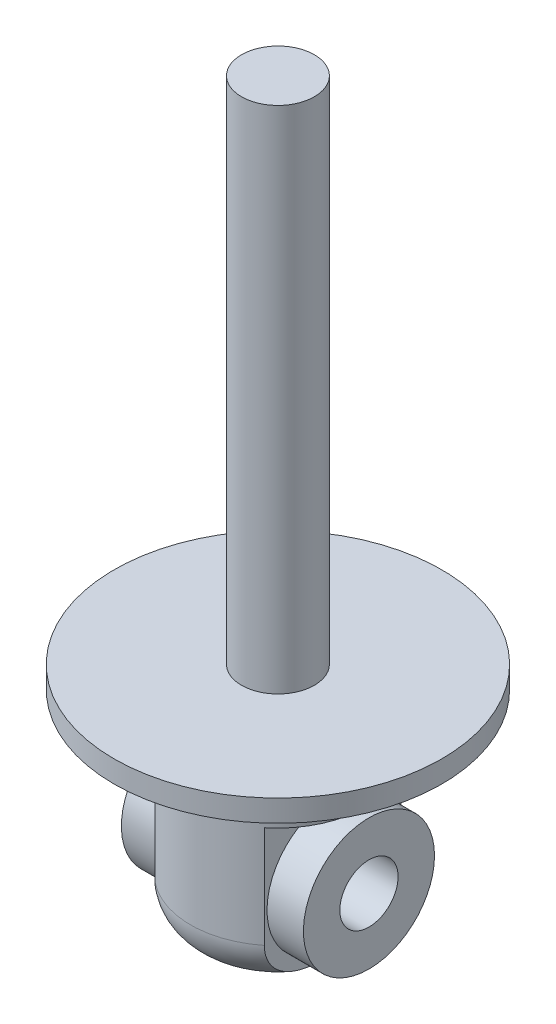
from build123d import *

# Parameters (mm, degrees)
SKETCH1_R               = 22.5
BOSS_EXTRUDE1_DEPTH     = 3
SKETCH2_R               = 5
BOSS_EXTRUDE2_DEPTH     = 70
SKETCH3_R               = 12
BOSS_EXTRUDE3_DEPTH     = 28
FILLET1_R               = 6
SKETCH4_W               = 19.983426231
SKETCH4_H               = 20
CUT_EXTRUDE1_DEPTH      = 23.5
CUT_EXTRUDE1_DEPTH_BACK = 23.5
SKETCH5_R               = 4
CUT_EXTRUDE2_DEPTH      = 16
CUT_EXTRUDE2_DEPTH_BACK = 31
SKETCH7_R               = 9
SKETCH7_R_2             = 4
BOSS_EXTRUDE5_DEPTH     = 12.5


with BuildPart() as part:
    # Sketch1 → Boss-Extrude1 (new body)
    with BuildSketch(Plane(origin=(0, 0, 0), x_dir=(1, 0, 0), z_dir=(0, 1, 0))):
        Circle(SKETCH1_R)
    extrude(amount=BOSS_EXTRUDE1_DEPTH)

    # Sketch2 → Boss-Extrude2 (add)
    with BuildSketch(Plane(origin=(0, 3, 0), x_dir=(1, 0, 0), z_dir=(0, 1, 0))):
        Circle(SKETCH2_R)
    extrude(amount=BOSS_EXTRUDE2_DEPTH)

    # Sketch3 → Boss-Extrude3 (add)
    with BuildSketch(Plane.XZ):
        Circle(SKETCH3_R)
    extrude(amount=BOSS_EXTRUDE3_DEPTH)

    # Fillet1
    fillet1_edges = [part.edges().sort_by_distance(p)[0] for p in [
        (-12, -28, 0),
    ]]
    fillet(fillet1_edges, radius=FILLET1_R)

    # Sketch4 → Cut-Extrude1 (cut, two sides)
    with BuildSketch(Plane.XY) as cut_extrude1_sk:
        with Locations((17.491713116, -18)):
            Rectangle(SKETCH4_W, SKETCH4_H)
        with Locations((-17.491713116, -18)):
            Rectangle(SKETCH4_W, SKETCH4_H)
    extrude(amount=CUT_EXTRUDE1_DEPTH, mode=Mode.SUBTRACT)
    extrude(cut_extrude1_sk.sketch, amount=-CUT_EXTRUDE1_DEPTH_BACK, mode=Mode.SUBTRACT)

    # Sketch5 → Cut-Extrude2 (cut, two sides)
    with BuildSketch(Plane(origin=(7.5, 0, 0), x_dir=(0, 0, -1), z_dir=(1, 0, 0))) as cut_extrude2_sk:
        with Locations((0, -18)):
            Circle(SKETCH5_R)
    extrude(amount=CUT_EXTRUDE2_DEPTH, mode=Mode.SUBTRACT)
    extrude(cut_extrude2_sk.sketch, amount=-CUT_EXTRUDE2_DEPTH_BACK, mode=Mode.SUBTRACT)

    # Sketch7 → Boss-Extrude5 (add, symmetric)
    with BuildSketch(Plane(origin=(0, 0, 0), x_dir=(0, 0, -1), z_dir=(1, 0, 0))):
        with Locations((0, -18)):
            Circle(SKETCH7_R)
        with Locations((0, -18)):
            Circle(SKETCH7_R_2, mode=Mode.SUBTRACT)
    extrude(amount=BOSS_EXTRUDE5_DEPTH, both=True)


solid = part.part
